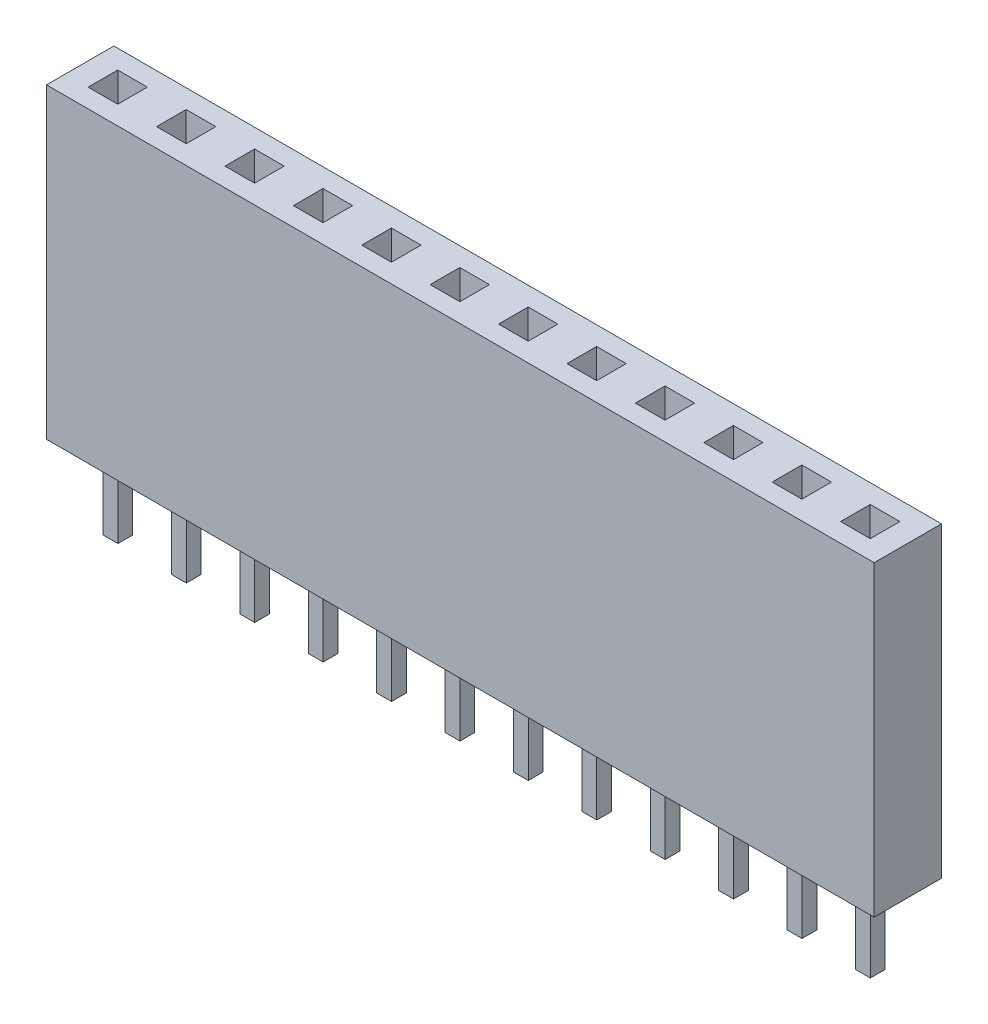
from build123d import *

# Parameters (mm, degrees)
SKETCH1_W              = 30.73
SKETCH1_H              = 11.4
BOSS_EXTRUDE1_DEPTH    = 1.25
SKETCH2_W              = 1.1
SKETCH2_H              = 1.1
CUT_EXTRUDE1_DEPTH     = 33.800234755
SKETCH3_W              = 30.73
SKETCH3_H              = 2.5
BOSS_EXTRUDE2_DEPTH    = 1
SKETCH4_W              = 0.55
SKETCH4_H              = 0.55
BOSS_EXTRUDE3_DEPTH    = 3
BOSS_EXTRUDE3_2_DEPTH  = 3
BOSS_EXTRUDE3_3_DEPTH  = 3
BOSS_EXTRUDE3_4_DEPTH  = 3
BOSS_EXTRUDE3_5_DEPTH  = 3
BOSS_EXTRUDE3_6_DEPTH  = 3
BOSS_EXTRUDE3_7_DEPTH  = 3
BOSS_EXTRUDE3_8_DEPTH  = 3
BOSS_EXTRUDE3_9_DEPTH  = 3
BOSS_EXTRUDE3_10_DEPTH = 3
BOSS_EXTRUDE3_11_DEPTH = 3
BOSS_EXTRUDE3_12_DEPTH = 3


with BuildPart() as part:
    # Sketch1 → Boss-Extrude1 (new, symmetric)
    with BuildSketch(Plane.XY):
        with Locations((15.365, 5.7)):
            Rectangle(SKETCH1_W, SKETCH1_H)
    extrude(amount=BOSS_EXTRUDE1_DEPTH, both=True)

    # Sketch2 → Cut-Extrude1 (cut, through all)
    with BuildSketch(Plane.XZ):
        with Locations((3.935, 0)):
            Rectangle(SKETCH2_W, SKETCH2_H)
        with Locations((1.395, 0)):
            Rectangle(SKETCH2_W, SKETCH2_H)
        with Locations((6.475, 0)):
            Rectangle(SKETCH2_W, SKETCH2_H)
        with Locations((9.015, 0)):
            Rectangle(SKETCH2_W, SKETCH2_H)
        with Locations((11.555, 0)):
            Rectangle(SKETCH2_W, SKETCH2_H)
        with Locations((14.095, 0)):
            Rectangle(SKETCH2_W, SKETCH2_H)
        with Locations((16.635, 0)):
            Rectangle(SKETCH2_W, SKETCH2_H)
        with Locations((19.175, 0)):
            Rectangle(SKETCH2_W, SKETCH2_H)
        with Locations((21.715, 0)):
            Rectangle(SKETCH2_W, SKETCH2_H)
        with Locations((24.255, 0)):
            Rectangle(SKETCH2_W, SKETCH2_H)
        with Locations((26.795, 0)):
            Rectangle(SKETCH2_W, SKETCH2_H)
        with Locations((29.335, 0)):
            Rectangle(SKETCH2_W, SKETCH2_H)
    extrude(amount=-CUT_EXTRUDE1_DEPTH, mode=Mode.SUBTRACT)

    # Sketch3 → Boss-Extrude2 (add)
    with BuildSketch(Plane.XZ):
        with Locations((15.365, 0)):
            Rectangle(SKETCH3_W, SKETCH3_H)
    extrude(amount=-BOSS_EXTRUDE2_DEPTH)


with BuildPart() as body_2:
    # Sketch4 → Boss-Extrude3 (new body)
    with BuildSketch(Plane.XZ):
        with Locations((1.4, 0)):
            Rectangle(SKETCH4_W, SKETCH4_H)
    extrude(amount=BOSS_EXTRUDE3_DEPTH)


with BuildPart() as body_3:
    # Sketch4 → Boss-Extrude3 2 (new body)
    with BuildSketch(Plane.XZ):
        with Locations((3.94, 0)):
            Rectangle(SKETCH4_W, SKETCH4_H)
    extrude(amount=BOSS_EXTRUDE3_2_DEPTH)


with BuildPart() as body_4:
    # Sketch4 → Boss-Extrude3 3 (new body)
    with BuildSketch(Plane.XZ):
        with Locations((6.48, 0)):
            Rectangle(SKETCH4_W, SKETCH4_H)
    extrude(amount=BOSS_EXTRUDE3_3_DEPTH)


with BuildPart() as body_5:
    # Sketch4 → Boss-Extrude3 4 (new body)
    with BuildSketch(Plane.XZ):
        with Locations((9.02, 0)):
            Rectangle(SKETCH4_W, SKETCH4_H)
    extrude(amount=BOSS_EXTRUDE3_4_DEPTH)


with BuildPart() as body_6:
    # Sketch4 → Boss-Extrude3 5 (new body)
    with BuildSketch(Plane.XZ):
        with Locations((11.56, 0)):
            Rectangle(SKETCH4_W, SKETCH4_H)
    extrude(amount=BOSS_EXTRUDE3_5_DEPTH)


with BuildPart() as body_7:
    # Sketch4 → Boss-Extrude3 6 (new body)
    with BuildSketch(Plane.XZ):
        with Locations((14.1, 0)):
            Rectangle(SKETCH4_W, SKETCH4_H)
    extrude(amount=BOSS_EXTRUDE3_6_DEPTH)


with BuildPart() as body_8:
    # Sketch4 → Boss-Extrude3 7 (new body)
    with BuildSketch(Plane.XZ):
        with Locations((16.64, 0)):
            Rectangle(SKETCH4_W, SKETCH4_H)
    extrude(amount=BOSS_EXTRUDE3_7_DEPTH)


with BuildPart() as body_9:
    # Sketch4 → Boss-Extrude3 8 (new body)
    with BuildSketch(Plane.XZ):
        with Locations((19.18, 0)):
            Rectangle(SKETCH4_W, SKETCH4_H)
    extrude(amount=BOSS_EXTRUDE3_8_DEPTH)


with BuildPart() as body_10:
    # Sketch4 → Boss-Extrude3 9 (new body)
    with BuildSketch(Plane.XZ):
        with Locations((21.72, 0)):
            Rectangle(SKETCH4_W, SKETCH4_H)
    extrude(amount=BOSS_EXTRUDE3_9_DEPTH)


with BuildPart() as body_11:
    # Sketch4 → Boss-Extrude3 10 (new body)
    with BuildSketch(Plane.XZ):
        with Locations((24.26, 0)):
            Rectangle(SKETCH4_W, SKETCH4_H)
    extrude(amount=BOSS_EXTRUDE3_10_DEPTH)


with BuildPart() as body_12:
    # Sketch4 → Boss-Extrude3 11 (new body)
    with BuildSketch(Plane.XZ):
        with Locations((26.8, 0)):
            Rectangle(SKETCH4_W, SKETCH4_H)
    extrude(amount=BOSS_EXTRUDE3_11_DEPTH)


with BuildPart() as body_13:
    # Sketch4 → Boss-Extrude3 12 (new body)
    with BuildSketch(Plane.XZ):
        with Locations((29.34, 0)):
            Rectangle(SKETCH4_W, SKETCH4_H)
    extrude(amount=BOSS_EXTRUDE3_12_DEPTH)


solid = Compound([part.part, body_2.part, body_3.part, body_4.part, body_5.part, body_6.part, body_7.part, body_8.part, body_9.part, body_10.part, body_11.part, body_12.part, body_13.part])
